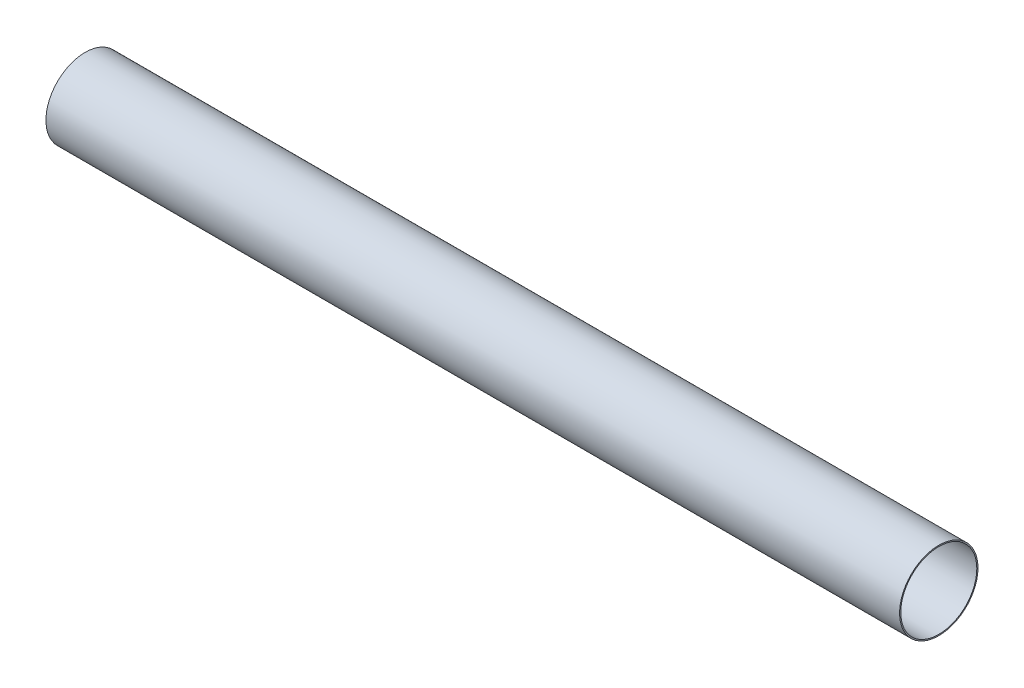
from build123d import *

# Parameters (mm, degrees)
SKETCH1_R           = 26.19375
SKETCH1_R_2         = 25.4
BOSS_EXTRUDE1_DEPTH = 285.115


with BuildPart() as part:
    # Sketch1 → Boss-Extrude1 (new body, symmetric)
    with BuildSketch(Plane(origin=(0, 0, 0), x_dir=(0, 0, -1), z_dir=(1, 0, 0))):
        Circle(SKETCH1_R)
        Circle(SKETCH1_R_2, mode=Mode.SUBTRACT)
    extrude(amount=BOSS_EXTRUDE1_DEPTH, both=True)


solid = part.part
